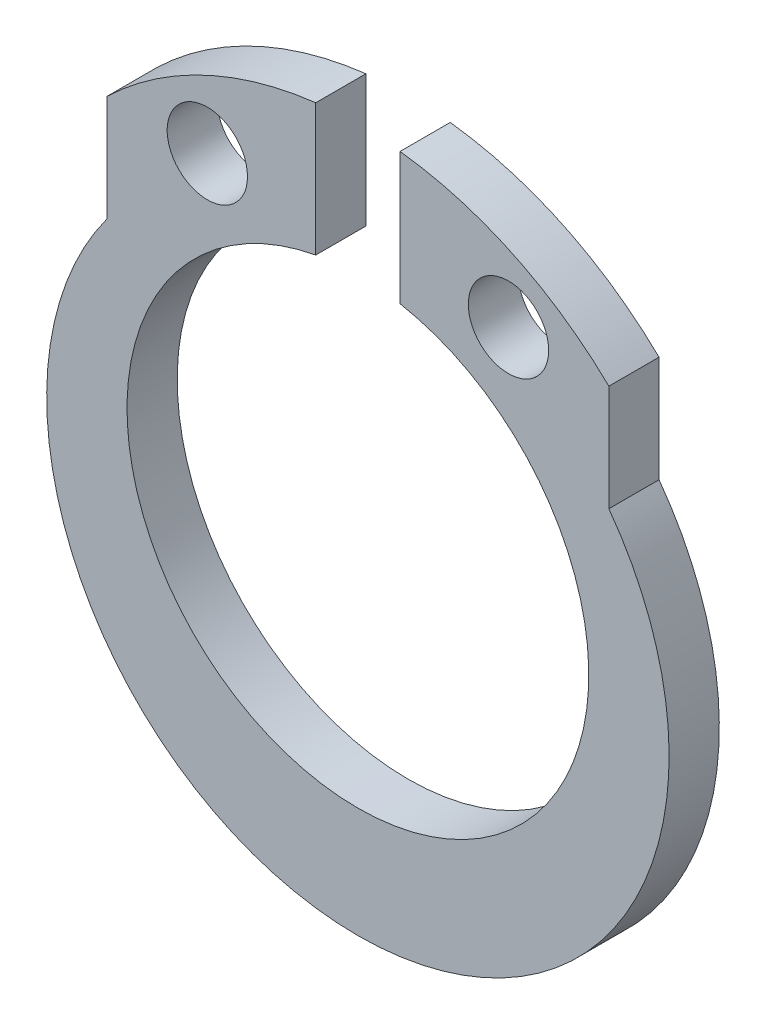
from build123d import *

# Parameters (mm, degrees)
BOSS_EXTRUDE1_DEPTH            = 0.5
SKETCH2_R                      = 2.3
CUT_EXTRUDE1_DEPTH             = 1.5
CUT_EXTRUDE2_DEPTH             = 1.5
F_0_8_0_8_DIAMETER_HOLE1_D     = 0.8
F_0_8_0_8_DIAMETER_HOLE1_DEPTH = 0.5


with BuildPart() as part:
    # Sketch1 → Boss-Extrude1 (new body)
    with BuildSketch(Plane.XY):
        with BuildLine():
            Line((-2.5, 2.890366769), (-2.5, 1.833030278))
            ThreePointArc((-2.5, 1.833030278), (0, -3.1), (2.5, 1.833030278))
            Line((2.5, 1.833030278), (2.5, 2.890366769))
            ThreePointArc((2.5, 2.890366769), (0, 3.9), (-2.5, 2.890366769))
        make_face()
    extrude(amount=-BOSS_EXTRUDE1_DEPTH)

    # Sketch2 → Cut-Extrude1 (cut, through all)
    with BuildSketch(Plane.XY):
        with Locations((0, 0.3)):
            Circle(SKETCH2_R)
    extrude(amount=-CUT_EXTRUDE1_DEPTH, mode=Mode.SUBTRACT)

    # Sketch3 → Cut-Extrude2 (cut, through all)
    with BuildSketch(Plane.XY):
        with BuildLine():
            Line((-0.42, 3.87541606), (-0.42, 2.561327044))
            ThreePointArc((-0.42, 2.561327044), (0, 2.6), (0.42, 2.561327044))
            Line((0.42, 2.561327044), (0.42, 3.87541606))
            ThreePointArc((0.42, 3.87541606), (0, 3.9), (-0.42, 3.87541606))
        make_face()
    extrude(amount=-CUT_EXTRUDE2_DEPTH, mode=Mode.SUBTRACT)

    # Ø0.8 (0.8) Diameter Hole1
    with Locations(Plane.XY):
        with Locations((-1.5, 2.898076211), (1.5, 2.898076211)):
            Hole(F_0_8_0_8_DIAMETER_HOLE1_D / 2, depth=F_0_8_0_8_DIAMETER_HOLE1_DEPTH)


solid = part.part
